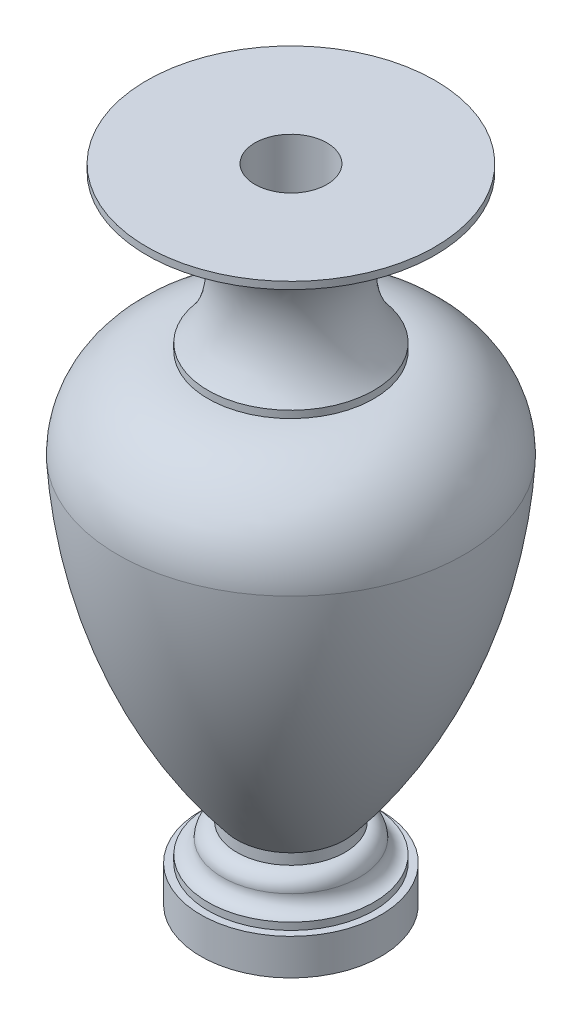
from build123d import *


with BuildPart() as part:
    # Sketch1 → Revolve1 (revolve)
    with BuildSketch(Plane.XY):
        with BuildLine():
            Line((0, 0), (25000, 0))
            Line((25000, 0), (25000, 10000))
            Line((25000, 10000), (23000, 10000))
            Line((23000, 10000), (23000, 12000))
            ThreePointArc((23000, 12000), (20171.572875254, 13171.572875254), (19000, 16000))
            ThreePointArc((19000, 16000), (17828.427124746, 18828.427124746), (15000, 20000))
            Line((15000, 20000), (15000, 23000))
            ThreePointArc((15000, 23000), (38208.497027298, 62894.602675502), (47999.37786084, 107998.397520345))
            ThreePointArc((47999.37786084, 107998.397520345), (40677.229610845, 125675.627131189), (23000, 132997.775381184))
            Line((23000, 132997.775381184), (23000, 135000))
            ThreePointArc((23000, 135000), (16781.639970993, 151500), (23000, 168000))
            Line((23000, 168000), (23000, 171000))
            ThreePointArc((23000, 171000), (26535.533905933, 172464.466094067), (28000, 176000))
            Line((28000, 176000), (40000, 176000))
            Line((40000, 176000), (40000, 178000))
            Line((40000, 178000), (10000, 178000))
            Line((10000, 178000), (10000, 95000))
            ThreePointArc((10000, 95000), (7071.067811865, 87928.932188135), (0, 85000))
            Line((0, 85000), (0, 0))
        make_face()
    revolve(axis=Axis((0, 0, 0), (0, 1, 0)))


solid = part.part
